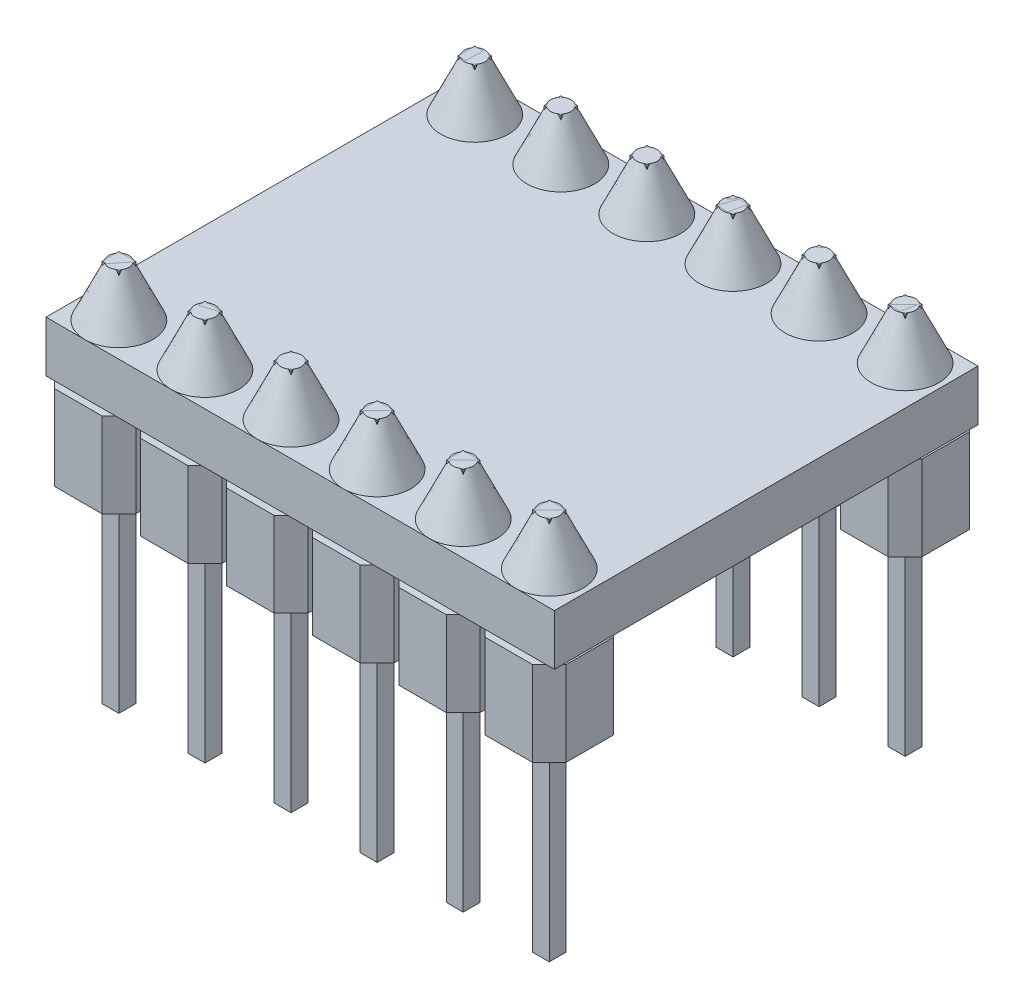
from build123d import *

# Parameters (mm, degrees)
SKETCH1_W             = 15
SKETCH1_H             = 12.5
PCB_DEPTH             = 1.5
SKETCH2_W             = 0.5
SKETCH2_H             = 0.5
PINS_DEPTH            = 1.5
PINS_DEPTH_BACK       = 9.8
PINS_2_DEPTH          = 1.5
PINS_2_DEPTH_BACK     = 9.8
PINS_3_DEPTH          = 1.5
PINS_3_DEPTH_BACK     = 9.8
PINS_4_DEPTH          = 1.5
PINS_4_DEPTH_BACK     = 9.8
PINS_5_DEPTH          = 1.5
PINS_5_DEPTH_BACK     = 9.8
PINS_6_DEPTH          = 1.5
PINS_6_DEPTH_BACK     = 9.8
PINS_7_DEPTH          = 1.5
PINS_7_DEPTH_BACK     = 9.8
PINS_8_DEPTH          = 1.5
PINS_8_DEPTH_BACK     = 9.8
PINS_9_DEPTH          = 1.5
PINS_9_DEPTH_BACK     = 9.8
PINS_10_DEPTH         = 1.5
PINS_10_DEPTH_BACK    = 9.8
PINS_11_DEPTH         = 1.5
PINS_11_DEPTH_BACK    = 9.8
PINS_12_DEPTH         = 1.5
PINS_12_DEPTH_BACK    = 9.8
PIN_SUPPORTS_DEPTH    = 2.5
PIN_SUPPORTS_2_DEPTH  = 2.5
PIN_SUPPORTS_3_DEPTH  = 2.5
PIN_SUPPORTS_4_DEPTH  = 2.5
PIN_SUPPORTS_5_DEPTH  = 2.5
PIN_SUPPORTS_6_DEPTH  = 2.5
PIN_SUPPORTS_7_DEPTH  = 2.5
PIN_SUPPORTS_8_DEPTH  = 2.5
PIN_SUPPORTS_9_DEPTH  = 2.5
PIN_SUPPORTS_10_DEPTH = 2.5
PIN_SUPPORTS_11_DEPTH = 2.5
PIN_SUPPORTS_12_DEPTH = 2.5
SKETCH4_R             = 1
SOLDERS_DEPTH         = 1.5
SOLDERS_TAPER         = 25
SOLDERS_2_DEPTH       = 1.5
SOLDERS_2_TAPER       = 25
SOLDERS_3_DEPTH       = 1.5
SOLDERS_3_TAPER       = 25
SOLDERS_4_DEPTH       = 1.5
SOLDERS_4_TAPER       = 25
SOLDERS_5_DEPTH       = 1.5
SOLDERS_5_TAPER       = 25
SOLDERS_6_DEPTH       = 1.5
SOLDERS_6_TAPER       = 25
SOLDERS_7_DEPTH       = 1.5
SOLDERS_7_TAPER       = 25
SOLDERS_8_DEPTH       = 1.5
SOLDERS_8_TAPER       = 25
SOLDERS_9_DEPTH       = 1.5
SOLDERS_9_TAPER       = 25
SOLDERS_10_DEPTH      = 1.5
SOLDERS_10_TAPER      = 25
SOLDERS_11_DEPTH      = 1.5
SOLDERS_11_TAPER      = 25
SOLDERS_12_DEPTH      = 1.5
SOLDERS_12_TAPER      = 25


with BuildPart() as part:
    # Sketch1 → pcb (new body)
    with BuildSketch(Plane(origin=(0, 0, 0), x_dir=(1, 0, 0), z_dir=(0, 1, 0))):
        Rectangle(SKETCH1_W, SKETCH1_H)
    extrude(amount=PCB_DEPTH)


with BuildPart() as body_2:
    # Sketch2 → pins (new body, two sides)
    with BuildSketch(Plane(origin=(0, 1.5, 0), x_dir=(1, 0, 0), z_dir=(0, 1, 0))) as pins_sk:
        with Locations((-6.35, 5.25)):
            Rectangle(SKETCH2_W, SKETCH2_H)
    extrude(amount=PINS_DEPTH)
    extrude(pins_sk.sketch, amount=-PINS_DEPTH_BACK)


with BuildPart() as body_3:
    # Sketch2 → pins 2 (new body, two sides)
    with BuildSketch(Plane(origin=(0, 1.5, 0), x_dir=(1, 0, 0), z_dir=(0, 1, 0))) as pins_2_sk:
        with Locations((-6.35, -5.25)):
            Rectangle(SKETCH2_W, SKETCH2_H)
    extrude(amount=PINS_2_DEPTH)
    extrude(pins_2_sk.sketch, amount=-PINS_2_DEPTH_BACK)


with BuildPart() as body_4:
    # Sketch2 → pins 3 (new body, two sides)
    with BuildSketch(Plane(origin=(0, 1.5, 0), x_dir=(1, 0, 0), z_dir=(0, 1, 0))) as pins_3_sk:
        with Locations((-3.81, 5.25)):
            Rectangle(SKETCH2_W, SKETCH2_H)
    extrude(amount=PINS_3_DEPTH)
    extrude(pins_3_sk.sketch, amount=-PINS_3_DEPTH_BACK)


with BuildPart() as body_5:
    # Sketch2 → pins 4 (new body, two sides)
    with BuildSketch(Plane(origin=(0, 1.5, 0), x_dir=(1, 0, 0), z_dir=(0, 1, 0))) as pins_4_sk:
        with Locations((-3.81, -5.25)):
            Rectangle(SKETCH2_W, SKETCH2_H)
    extrude(amount=PINS_4_DEPTH)
    extrude(pins_4_sk.sketch, amount=-PINS_4_DEPTH_BACK)


with BuildPart() as body_6:
    # Sketch2 → pins 5 (new body, two sides)
    with BuildSketch(Plane(origin=(0, 1.5, 0), x_dir=(1, 0, 0), z_dir=(0, 1, 0))) as pins_5_sk:
        with Locations((-1.27, 5.25)):
            Rectangle(SKETCH2_W, SKETCH2_H)
    extrude(amount=PINS_5_DEPTH)
    extrude(pins_5_sk.sketch, amount=-PINS_5_DEPTH_BACK)


with BuildPart() as body_7:
    # Sketch2 → pins 6 (new body, two sides)
    with BuildSketch(Plane(origin=(0, 1.5, 0), x_dir=(1, 0, 0), z_dir=(0, 1, 0))) as pins_6_sk:
        with Locations((-1.27, -5.25)):
            Rectangle(SKETCH2_W, SKETCH2_H)
    extrude(amount=PINS_6_DEPTH)
    extrude(pins_6_sk.sketch, amount=-PINS_6_DEPTH_BACK)


with BuildPart() as body_8:
    # Sketch2 → pins 7 (new body, two sides)
    with BuildSketch(Plane(origin=(0, 1.5, 0), x_dir=(1, 0, 0), z_dir=(0, 1, 0))) as pins_7_sk:
        with Locations((1.27, 5.25)):
            Rectangle(SKETCH2_W, SKETCH2_H)
    extrude(amount=PINS_7_DEPTH)
    extrude(pins_7_sk.sketch, amount=-PINS_7_DEPTH_BACK)


with BuildPart() as body_9:
    # Sketch2 → pins 8 (new body, two sides)
    with BuildSketch(Plane(origin=(0, 1.5, 0), x_dir=(1, 0, 0), z_dir=(0, 1, 0))) as pins_8_sk:
        with Locations((1.27, -5.25)):
            Rectangle(SKETCH2_W, SKETCH2_H)
    extrude(amount=PINS_8_DEPTH)
    extrude(pins_8_sk.sketch, amount=-PINS_8_DEPTH_BACK)


with BuildPart() as body_10:
    # Sketch2 → pins 9 (new body, two sides)
    with BuildSketch(Plane(origin=(0, 1.5, 0), x_dir=(1, 0, 0), z_dir=(0, 1, 0))) as pins_9_sk:
        with Locations((3.81, 5.25)):
            Rectangle(SKETCH2_W, SKETCH2_H)
    extrude(amount=PINS_9_DEPTH)
    extrude(pins_9_sk.sketch, amount=-PINS_9_DEPTH_BACK)


with BuildPart() as body_11:
    # Sketch2 → pins 10 (new body, two sides)
    with BuildSketch(Plane(origin=(0, 1.5, 0), x_dir=(1, 0, 0), z_dir=(0, 1, 0))) as pins_10_sk:
        with Locations((3.81, -5.25)):
            Rectangle(SKETCH2_W, SKETCH2_H)
    extrude(amount=PINS_10_DEPTH)
    extrude(pins_10_sk.sketch, amount=-PINS_10_DEPTH_BACK)


with BuildPart() as body_12:
    # Sketch2 → pins 11 (new body, two sides)
    with BuildSketch(Plane(origin=(0, 1.5, 0), x_dir=(1, 0, 0), z_dir=(0, 1, 0))) as pins_11_sk:
        with Locations((6.35, 5.25)):
            Rectangle(SKETCH2_W, SKETCH2_H)
    extrude(amount=PINS_11_DEPTH)
    extrude(pins_11_sk.sketch, amount=-PINS_11_DEPTH_BACK)


with BuildPart() as body_13:
    # Sketch2 → pins 12 (new body, two sides)
    with BuildSketch(Plane(origin=(0, 1.5, 0), x_dir=(1, 0, 0), z_dir=(0, 1, 0))) as pins_12_sk:
        with Locations((6.35, -5.25)):
            Rectangle(SKETCH2_W, SKETCH2_H)
    extrude(amount=PINS_12_DEPTH)
    extrude(pins_12_sk.sketch, amount=-PINS_12_DEPTH_BACK)


with BuildPart() as body_14:
    # Sketch3 → pin_supports (new body)
    with BuildSketch(Plane.XZ):
        Polygon((-5.65, 4.05), (-7.05, 4.05), (-7.55, 4.55), (-7.55, 5.95), (-7.05, 6.45), (-5.65, 6.45), (-5.15, 5.95), (-5.15, 4.55), align=None)
    extrude(amount=PIN_SUPPORTS_DEPTH)


with BuildPart() as body_15:
    # Sketch3 → pin_supports 2 (new body)
    with BuildSketch(Plane.XZ):
        Polygon((-5.65, -6.45), (-7.05, -6.45), (-7.55, -5.95), (-7.55, -4.55), (-7.05, -4.05), (-5.65, -4.05), (-5.15, -4.55), (-5.15, -5.95), align=None)
    extrude(amount=PIN_SUPPORTS_2_DEPTH)


with BuildPart() as body_16:
    # Sketch3 → pin_supports 3 (new body)
    with BuildSketch(Plane.XZ):
        Polygon((-2.61, 4.55), (-2.61, 5.95), (-3.11, 6.45), (-4.51, 6.45), (-5.01, 5.95), (-5.01, 4.55), (-4.51, 4.05), (-3.11, 4.05), align=None)
    extrude(amount=PIN_SUPPORTS_3_DEPTH)


with BuildPart() as body_17:
    # Sketch3 → pin_supports 4 (new body)
    with BuildSketch(Plane.XZ):
        Polygon((-3.11, -6.45), (-4.51, -6.45), (-5.01, -5.95), (-5.01, -4.55), (-4.51, -4.05), (-3.11, -4.05), (-2.61, -4.55), (-2.61, -5.95), align=None)
    extrude(amount=PIN_SUPPORTS_4_DEPTH)


with BuildPart() as body_18:
    # Sketch3 → pin_supports 5 (new body)
    with BuildSketch(Plane.XZ):
        Polygon((-0.07, 4.55), (-0.07, 5.95), (-0.57, 6.45), (-1.97, 6.45), (-2.47, 5.95), (-2.47, 4.55), (-1.97, 4.05), (-0.57, 4.05), align=None)
    extrude(amount=PIN_SUPPORTS_5_DEPTH)


with BuildPart() as body_19:
    # Sketch3 → pin_supports 6 (new body)
    with BuildSketch(Plane.XZ):
        Polygon((-0.57, -6.45), (-1.97, -6.45), (-2.47, -5.95), (-2.47, -4.55), (-1.97, -4.05), (-0.57, -4.05), (-0.07, -4.55), (-0.07, -5.95), align=None)
    extrude(amount=PIN_SUPPORTS_6_DEPTH)


with BuildPart() as body_20:
    # Sketch3 → pin_supports 7 (new body)
    with BuildSketch(Plane.XZ):
        Polygon((2.47, 4.55), (2.47, 5.95), (1.97, 6.45), (0.57, 6.45), (0.07, 5.95), (0.07, 4.55), (0.57, 4.05), (1.97, 4.05), align=None)
    extrude(amount=PIN_SUPPORTS_7_DEPTH)


with BuildPart() as body_21:
    # Sketch3 → pin_supports 8 (new body)
    with BuildSketch(Plane.XZ):
        Polygon((1.97, -6.45), (0.57, -6.45), (0.07, -5.95), (0.07, -4.55), (0.57, -4.05), (1.97, -4.05), (2.47, -4.55), (2.47, -5.95), align=None)
    extrude(amount=PIN_SUPPORTS_8_DEPTH)


with BuildPart() as body_22:
    # Sketch3 → pin_supports 9 (new body)
    with BuildSketch(Plane.XZ):
        Polygon((5.01, 4.55), (5.01, 5.95), (4.51, 6.45), (3.11, 6.45), (2.61, 5.95), (2.61, 4.55), (3.11, 4.05), (4.51, 4.05), align=None)
    extrude(amount=PIN_SUPPORTS_9_DEPTH)


with BuildPart() as body_23:
    # Sketch3 → pin_supports 10 (new body)
    with BuildSketch(Plane.XZ):
        Polygon((4.51, -6.45), (3.11, -6.45), (2.61, -5.95), (2.61, -4.55), (3.11, -4.05), (4.51, -4.05), (5.01, -4.55), (5.01, -5.95), align=None)
    extrude(amount=PIN_SUPPORTS_10_DEPTH)


with BuildPart() as body_24:
    # Sketch3 → pin_supports 11 (new body)
    with BuildSketch(Plane.XZ):
        Polygon((7.55, 4.55), (7.55, 5.95), (7.05, 6.45), (5.65, 6.45), (5.15, 5.95), (5.15, 4.55), (5.65, 4.05), (7.05, 4.05), align=None)
    extrude(amount=PIN_SUPPORTS_11_DEPTH)


with BuildPart() as body_25:
    # Sketch3 → pin_supports 12 (new body)
    with BuildSketch(Plane.XZ):
        Polygon((7.05, -6.45), (5.65, -6.45), (5.15, -5.95), (5.15, -4.55), (5.65, -4.05), (7.05, -4.05), (7.55, -4.55), (7.55, -5.95), align=None)
    extrude(amount=PIN_SUPPORTS_12_DEPTH)


with BuildPart() as body_26:
    # Sketch4 → solders (new body)
    with BuildSketch(Plane(origin=(0, 1.5, 0), x_dir=(1, 0, 0), z_dir=(0, 1, 0))):
        with Locations((-6.35, -5.25)):
            Circle(SKETCH4_R)
    extrude(amount=SOLDERS_DEPTH, taper=SOLDERS_TAPER)


with BuildPart() as body_27:
    # Sketch4 → solders 2 (new body)
    with BuildSketch(Plane(origin=(0, 1.5, 0), x_dir=(1, 0, 0), z_dir=(0, 1, 0))):
        with Locations((-6.35, 5.25)):
            Circle(SKETCH4_R)
    extrude(amount=SOLDERS_2_DEPTH, taper=SOLDERS_2_TAPER)


with BuildPart() as body_28:
    # Sketch4 → solders 3 (new body)
    with BuildSketch(Plane(origin=(0, 1.5, 0), x_dir=(1, 0, 0), z_dir=(0, 1, 0))):
        with Locations((-3.81, -5.25)):
            Circle(SKETCH4_R)
    extrude(amount=SOLDERS_3_DEPTH, taper=SOLDERS_3_TAPER)


with BuildPart() as body_29:
    # Sketch4 → solders 4 (new body)
    with BuildSketch(Plane(origin=(0, 1.5, 0), x_dir=(1, 0, 0), z_dir=(0, 1, 0))):
        with Locations((-3.81, 5.25)):
            Circle(SKETCH4_R)
    extrude(amount=SOLDERS_4_DEPTH, taper=SOLDERS_4_TAPER)


with BuildPart() as body_30:
    # Sketch4 → solders 5 (new body)
    with BuildSketch(Plane(origin=(0, 1.5, 0), x_dir=(1, 0, 0), z_dir=(0, 1, 0))):
        with Locations((-1.27, -5.25)):
            Circle(SKETCH4_R)
    extrude(amount=SOLDERS_5_DEPTH, taper=SOLDERS_5_TAPER)


with BuildPart() as body_31:
    # Sketch4 → solders 6 (new body)
    with BuildSketch(Plane(origin=(0, 1.5, 0), x_dir=(1, 0, 0), z_dir=(0, 1, 0))):
        with Locations((-1.27, 5.25)):
            Circle(SKETCH4_R)
    extrude(amount=SOLDERS_6_DEPTH, taper=SOLDERS_6_TAPER)


with BuildPart() as body_32:
    # Sketch4 → solders 7 (new body)
    with BuildSketch(Plane(origin=(0, 1.5, 0), x_dir=(1, 0, 0), z_dir=(0, 1, 0))):
        with Locations((1.27, -5.25)):
            Circle(SKETCH4_R)
    extrude(amount=SOLDERS_7_DEPTH, taper=SOLDERS_7_TAPER)


with BuildPart() as body_33:
    # Sketch4 → solders 8 (new body)
    with BuildSketch(Plane(origin=(0, 1.5, 0), x_dir=(1, 0, 0), z_dir=(0, 1, 0))):
        with Locations((1.27, 5.25)):
            Circle(SKETCH4_R)
    extrude(amount=SOLDERS_8_DEPTH, taper=SOLDERS_8_TAPER)


with BuildPart() as body_34:
    # Sketch4 → solders 9 (new body)
    with BuildSketch(Plane(origin=(0, 1.5, 0), x_dir=(1, 0, 0), z_dir=(0, 1, 0))):
        with Locations((3.81, -5.25)):
            Circle(SKETCH4_R)
    extrude(amount=SOLDERS_9_DEPTH, taper=SOLDERS_9_TAPER)


with BuildPart() as body_35:
    # Sketch4 → solders 10 (new body)
    with BuildSketch(Plane(origin=(0, 1.5, 0), x_dir=(1, 0, 0), z_dir=(0, 1, 0))):
        with Locations((3.81, 5.25)):
            Circle(SKETCH4_R)
    extrude(amount=SOLDERS_10_DEPTH, taper=SOLDERS_10_TAPER)


with BuildPart() as body_36:
    # Sketch4 → solders 11 (new body)
    with BuildSketch(Plane(origin=(0, 1.5, 0), x_dir=(1, 0, 0), z_dir=(0, 1, 0))):
        with Locations((6.35, -5.25)):
            Circle(SKETCH4_R)
    extrude(amount=SOLDERS_11_DEPTH, taper=SOLDERS_11_TAPER)


with BuildPart() as body_37:
    # Sketch4 → solders 12 (new body)
    with BuildSketch(Plane(origin=(0, 1.5, 0), x_dir=(1, 0, 0), z_dir=(0, 1, 0))):
        with Locations((6.35, 5.25)):
            Circle(SKETCH4_R)
    extrude(amount=SOLDERS_12_DEPTH, taper=SOLDERS_12_TAPER)


solid = Compound([part.part, body_2.part, body_3.part, body_4.part, body_5.part, body_6.part, body_7.part, body_8.part, body_9.part, body_10.part, body_11.part, body_12.part, body_13.part, body_14.part, body_15.part, body_16.part, body_17.part, body_18.part, body_19.part, body_20.part, body_21.part, body_22.part, body_23.part, body_24.part, body_25.part, body_26.part, body_27.part, body_28.part, body_29.part, body_30.part, body_31.part, body_32.part, body_33.part, body_34.part, body_35.part, body_36.part, body_37.part])
